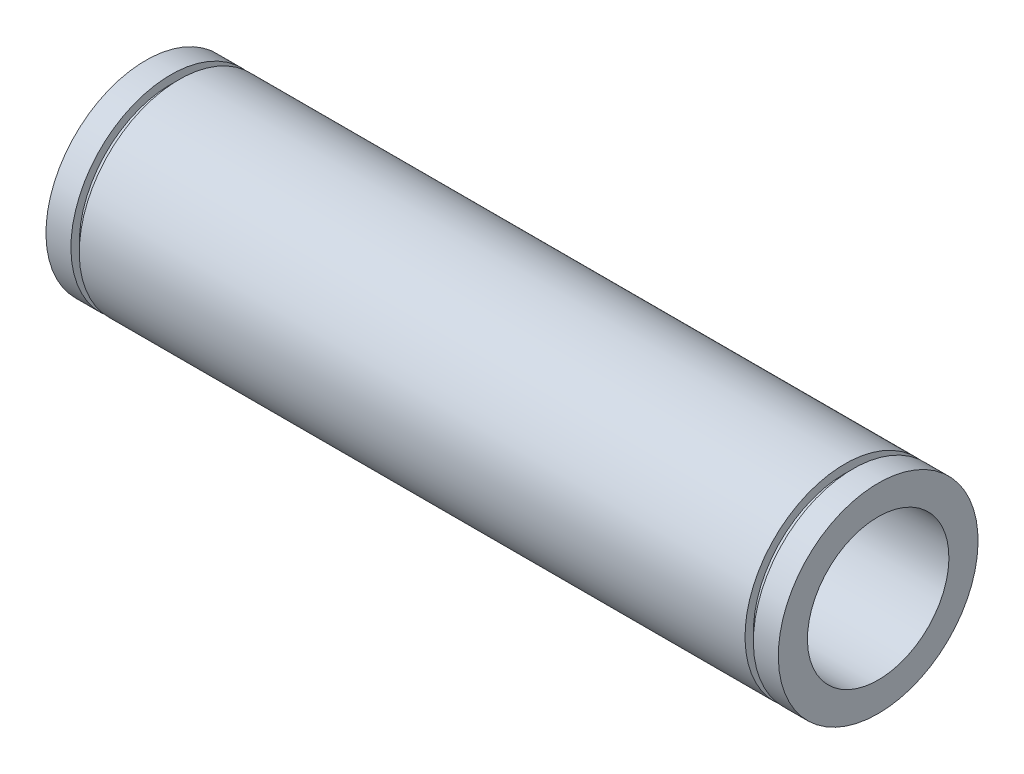
from build123d import *

# Parameters (mm, degrees)
IZIM2_R               = 8.5
KES_EKSTR_ZYON1_DEPTH = 89


with BuildPart() as part:
    # Çizim1 → Döndür1 (revolve)
    with BuildSketch(Plane.XY):
        Polygon((-44, 0), (-44, 12), (-41, 12), (-41, 11), (-40, 11), (-40, 12), (40, 12), (40, 11), (41, 11), (41, 12), (44, 12), (44, 0), align=None)
    revolve(axis=Axis((-44, 0, 0), (1, 0, 0)))

    # Çizim2 → Kes-Ekstrüzyon1 (cut, through all)
    with BuildSketch(Plane(origin=(44, 0, 0), x_dir=(0, 0, -1), z_dir=(1, 0, 0))):
        Circle(IZIM2_R)
    extrude(amount=-KES_EKSTR_ZYON1_DEPTH, mode=Mode.SUBTRACT)


solid = part.part
